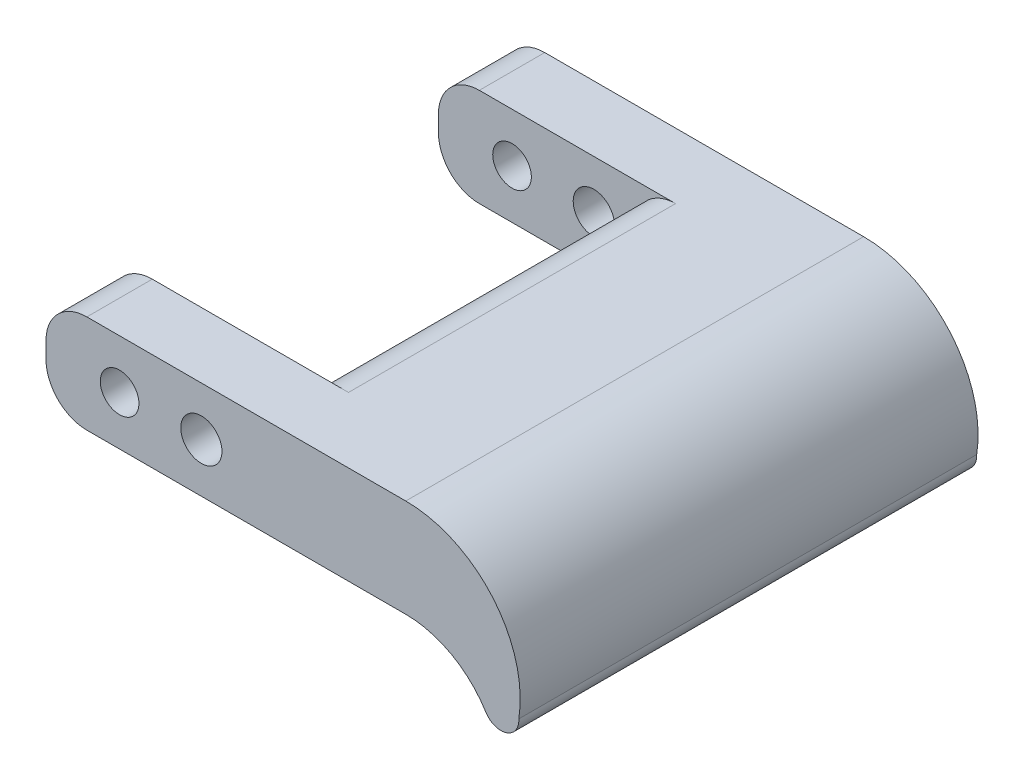
from build123d import *

# Parameters (mm, degrees)
BOSS_EXTRUDE1_DEPTH = 7.62
FILLET1_R           = 3.175
SKETCH2_R           = 1.5
SKETCH2_R_2         = 1.6
CUT_EXTRUDE1_DEPTH  = 36.56
BOSS_EXTRUDE2_DEPTH = 35.56


with BuildPart() as part:
    # Sketch1 → Boss-Extrude1 (new body)
    with BuildSketch(Plane(origin=(0, 0, 0), x_dir=(1, 0, 0), z_dir=(0, 1, 0))):
        Polygon((0, 5.08), (0, 0), (27.94, 0), (27.94, 35.56), (0, 35.56), (0, 30.48), (15.24, 30.48), (15.24, 5.08), align=None)
    extrude(amount=BOSS_EXTRUDE1_DEPTH)

    # Fillet1
    fillet1_edges = [part.edges().sort_by_distance(p)[0] for p in [
        (15.24, 7.62, -17.78),
        (0, 0, -2.54),
        (15.24, 0, -17.78),
        (0, 7.62, -2.54),
        (0, 7.62, -33.02),
        (0, 0, -33.02),
    ]]
    fillet(fillet1_edges, radius=FILLET1_R)

    # Sketch2 → Cut-Extrude1 (cut, through all)
    with BuildSketch(Plane.XY):
        with Locations((5.715, 3.81)):
            Circle(SKETCH2_R)
        with Locations((12.065, 3.81)):
            Circle(SKETCH2_R_2)
    extrude(amount=-CUT_EXTRUDE1_DEPTH, mode=Mode.SUBTRACT)

    # Sketch3 → Boss-Extrude2 (add)
    with BuildSketch(Plane.XY):
        with BuildLine():
            Line((27.94, 0), (27.94, 7.62))
            ThreePointArc((27.94, 7.62), (34.695471328, 4.50875779), (36.722362141, -2.647214162))
            ThreePointArc((36.722362141, -2.647214162), (35.75702901, -4.059087707), (34.153122917, -3.465168346))
            ThreePointArc((34.153122917, -3.465168346), (31.497045405, -0.924856567), (27.94, 0))
        make_face()
    extrude(amount=-BOSS_EXTRUDE2_DEPTH)


solid = part.part
